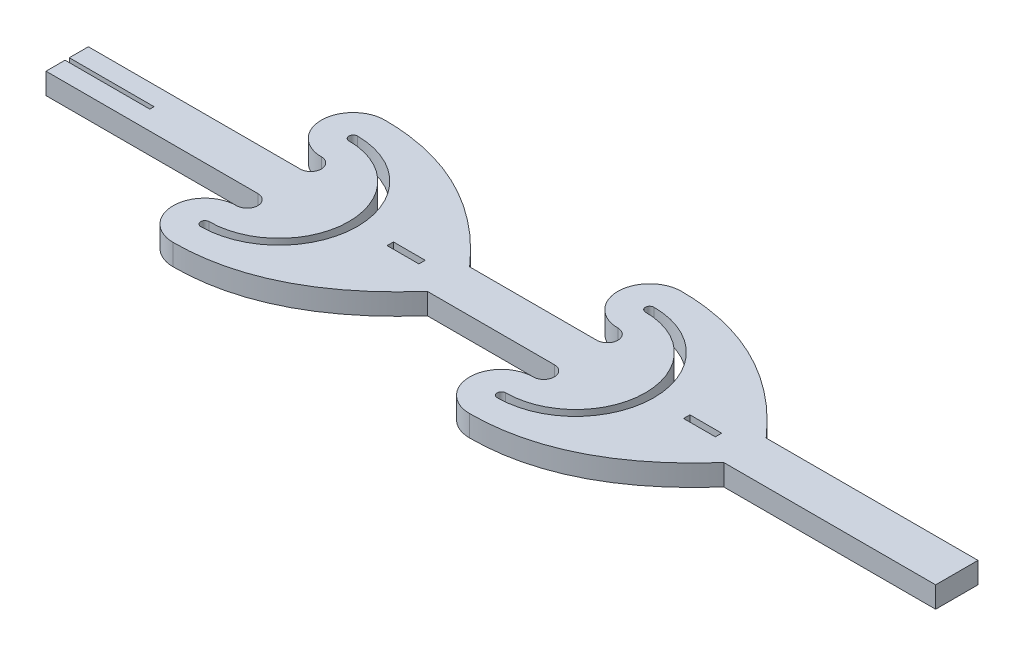
from build123d import *

# Parameters (mm, degrees)
BOSS_EXTRUDE1_DEPTH = 1
SKETCH2_W           = 1.5
SKETCH2_H           = 0.3
CUT_EXTRUDE1_DEPTH  = 1


with BuildPart() as part:
    # Sketch1 → Boss-Extrude1 (new body)
    with BuildSketch(Plane(origin=(0, 0, 0), x_dir=(1, 0, 0), z_dir=(0, 1, 0))):
        with BuildLine():
            Line((0, 1), (10, 1))
            ThreePointArc((10, 1), (10.499999999, 1.499999999), (10, 1.999999998))
            ThreePointArc((10, 1.999999998), (8.5, 3.499999998), (10, 4.999999998))
            add(Edge.make_bspline(
                [(10, 4.999999998), (14.475567746, 4.998166583), (17.999999995, 1)],
                knots=[0, 0, 0, 1, 1, 1], degree=2))
            Line((17.999999995, 1), (24, 1))
            ThreePointArc((24, 1), (24.499999999, 1.5), (24, 1.999999999))
            ThreePointArc((24, 1.999999999), (22.500000001, 3.500000002), (24.000000003, 5))
            add(Edge.make_bspline(
                [(24.000000003, 5), (28.47556775, 4.998166585), (31.999999998, 1)],
                knots=[0, 0, 0, 1, 1, 1], degree=2))
            Line((31.999999998, 1), (41.999999998, 1))
            Line((41.999999998, 1), (41.999999998, -1.000000004))
            Line((41.999999998, -1.000000004), (31.999999996, -1.000000004))
            add(Edge.make_bspline(
                [(23.999999999, -5), (28.475567744, -4.998166004), (31.999999996, -1.000000004)],
                knots=[0, 0, 0, 1, 1, 1], degree=2))
            ThreePointArc((23.999999999, -5), (22.499999999, -3.5), (23.999999999, -2))
            ThreePointArc((23.999999999, -2), (24.499999999, -1.5), (23.999999999, -1))
            Line((23.999999999, -1), (17.999999995, -1))
            add(Edge.make_bspline(
                [(10, -4.999999998), (14.475567746, -4.998166584), (17.999999995, -1)],
                knots=[0, 0, 0, 1, 1, 1], degree=2))
            ThreePointArc((10, -4.999999998), (8.50000001, -3.500000008), (10, -2.000000018))
            ThreePointArc((10, -2.000000018), (10.500000009, -1.500000009), (10, -1))
            Line((10, -1), (0, -1))
            Line((0, -1), (0, -0.1))
            Line((0, -0.1), (4, -0.1))
            Line((4, -0.1), (4, 0.1))
            Line((4, 0.1), (0, 0.1))
            Line((0, 0.1), (0, 1))
        make_face()
    extrude(amount=BOSS_EXTRUDE1_DEPTH)

    # Sketch2 → Cut-Extrude1 (cut)
    with BuildSketch(Plane(origin=(0, 1, 0), x_dir=(1, 0, 0), z_dir=(0, 1, 0))):
        with Locations((15.932882113, 0.071093436)):
            Rectangle(SKETCH2_W, SKETCH2_H)
        with Locations((30.000000004, 3e-09)):
            Rectangle(SKETCH2_W, SKETCH2_H)
        with BuildLine():
            ThreePointArc((10, -3.699999998), (13.699999998, 0), (10, 3.699999998))
            ThreePointArc((10, 3.699999998), (9.800000001, 3.499999999), (10, 3.3))
            ThreePointArc((10, 3.3), (13.3, 0), (10, -3.3))
            ThreePointArc((10, -3.3), (9.800000001, -3.499999999), (10, -3.699999998))
        make_face()
        with BuildLine():
            ThreePointArc((24, -3.699999998), (27.699999998, 0), (24, 3.699999998))
            ThreePointArc((24, 3.699999998), (23.8, 3.499999998), (24, 3.299999998))
            ThreePointArc((24, 3.299999998), (27.299999998, 0), (24, -3.299999998))
            ThreePointArc((24, -3.299999998), (23.8, -3.499999998), (24, -3.699999998))
        make_face()
    extrude(amount=-CUT_EXTRUDE1_DEPTH, mode=Mode.SUBTRACT)


solid = part.part
